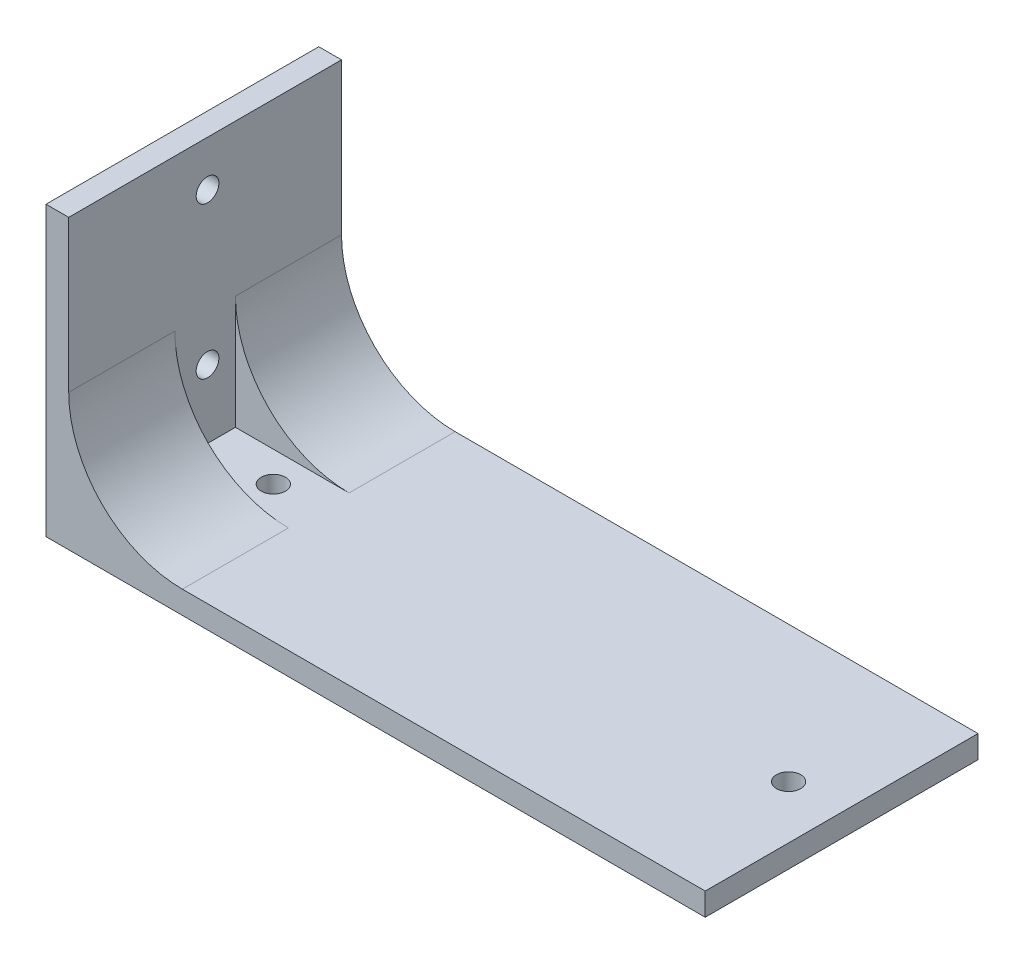
from build123d import *

# Parameters (mm, degrees)
SKETCH1_W           = 87
SKETCH1_H           = 36
SKETCH1_R           = 1.6
BOSS_EXTRUDE1_DEPTH = 3
SKETCH2_W           = 3
SKETCH2_H           = 14
BOSS_EXTRUDE2_DEPTH = 35
FILLET2_R           = 15
SKETCH3_W           = 3
SKETCH3_H           = 8
BOSS_EXTRUDE3_DEPTH = 35
SKETCH4_R           = 1.5
CUT_EXTRUDE1_DEPTH  = 30


with BuildPart() as part:
    # Sketch1 → Boss-Extrude1 (new body)
    with BuildSketch(Plane(origin=(0, 0, 0), x_dir=(1, 0, 0), z_dir=(0, 1, 0))):
        with Locations((10.275590551, -4.641732283)):
            Rectangle(SKETCH1_W, SKETCH1_H)
        with Locations((46.775590551, -4.641732283)):
            Circle(SKETCH1_R, mode=Mode.SUBTRACT)
        with Locations((-21.224409449, -4.641732283)):
            Circle(SKETCH1_R, mode=Mode.SUBTRACT)
    extrude(amount=BOSS_EXTRUDE1_DEPTH)

    # Sketch2 → Boss-Extrude2 (add)
    with BuildSketch(Plane(origin=(0, 3, 0), x_dir=(1, 0, 0), z_dir=(0, 1, 0))):
        with Locations((-31.724409449, 6.358267717)):
            Rectangle(SKETCH2_W, SKETCH2_H)
        with Locations((-31.724409449, -15.641732283)):
            Rectangle(SKETCH2_W, SKETCH2_H)
    extrude(amount=BOSS_EXTRUDE2_DEPTH)

    # Fillet2
    fillet2_edges = [part.edges().sort_by_distance(p)[0] for p in [
        (-30.224409449, 3, -6.358267717),
        (-30.224409449, 3, 15.641732283),
    ]]
    fillet(fillet2_edges, radius=FILLET2_R)

    # Sketch3 → Boss-Extrude3 (add)
    with BuildSketch(Plane(origin=(0, 3, 0), x_dir=(1, 0, 0), z_dir=(0, 1, 0))):
        with Locations((-31.724409449, -4.641732283)):
            Rectangle(SKETCH3_W, SKETCH3_H)
    extrude(amount=BOSS_EXTRUDE3_DEPTH)

    # Sketch4 → Cut-Extrude1 (cut)
    with BuildSketch(Plane(origin=(-30.224409449, 0, 0), x_dir=(0, 0, -1), z_dir=(1, 0, 0))):
        with Locations((-4.324534662, 32)):
            Circle(SKETCH4_R)
        with Locations((-4.324534662, 12)):
            Circle(SKETCH4_R)
    extrude(amount=-CUT_EXTRUDE1_DEPTH, mode=Mode.SUBTRACT)


solid = part.part
